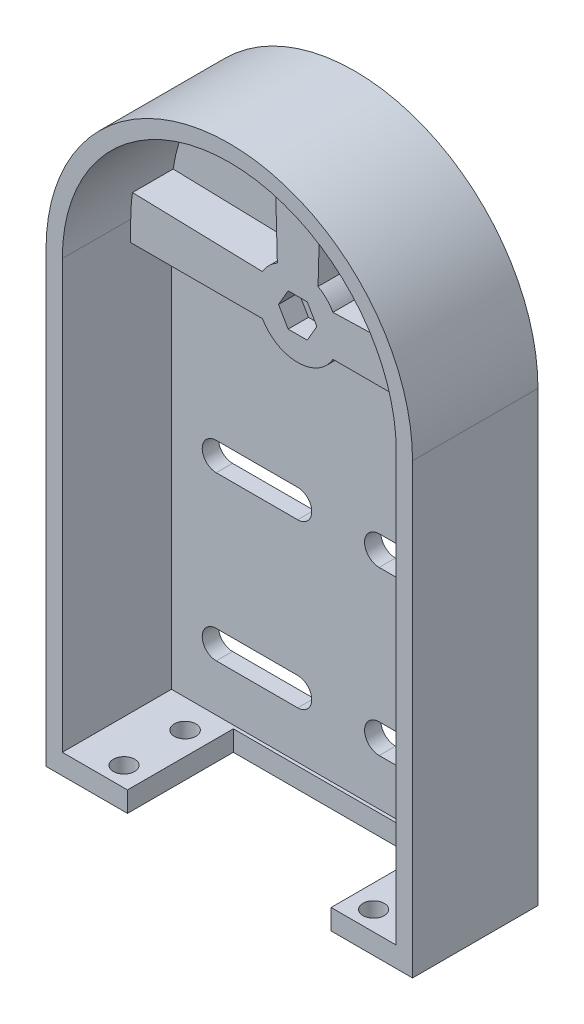
from build123d import *

# Parameters (mm, degrees)
SALIENTE_EXTRUIR1_DEPTH                              = 4
CROQUIS2_R                                           = 2.75
SALIENTE_EXTRUIR2_DEPTH                              = 10
SALIENTE_EXTRUIR3_DEPTH                              = 30.8
CROQUIS4_R                                           = 2.75
CORTAR_EXTRUIR1_DEPTH                                = 4
REFRENTADO_PARA_TORNILLO_TAP_N_CON_CABEZ_D           = 5.5
REFRENTADO_PARA_TORNILLO_TAP_N_CON_CABEZ_CSINK_D     = 11.2
REFRENTADO_PARA_TORNILLO_TAP_N_CON_CABEZ_CSINK_ANGLE = 90
CORTAR_EXTRUIR2_DEPTH                                = 5
CORTAR_EXTRUIR3_DEPTH                                = 5
CORTAR_EXTRUIR4_DEPTH                                = 14
CROQUIS10_W                                          = 82
CROQUIS10_H                                          = 26.8
SALIENTE_EXTRUIR4_DEPTH                              = 5
CROQUIS11_R                                          = 2.619714774
CROQUIS11_W                                          = 50
CROQUIS11_H                                          = 26
CROQUIS11_R_2                                        = 2.655214408
CORTAR_EXTRUIR5_DEPTH                                = 5


with BuildPart() as part:
    # Croquis1 → Saliente-Extruir1 (new body)
    with BuildSketch(Plane.XY):
        with BuildLine():
            Line((-41, 0), (41, 0))
            Line((41, 0), (41, 110))
            ThreePointArc((41, 110), (0, 151), (-41, 110))
            Line((-41, 110), (-41, 0))
        make_face()
    extrude(amount=SALIENTE_EXTRUIR1_DEPTH)

    # Croquis2 → Saliente-Extruir2 (add)
    with BuildSketch(Plane.XY.offset(4)):
        with BuildLine():
            Line((-41, 105), (-8.660254038, 105))
            ThreePointArc((-8.660254038, 105), (0, 100), (8.660254038, 105))
            Line((8.660254038, 105), (41, 105))
            Line((41, 105), (41, 110))
            ThreePointArc((41, 110), (40.894733882, 112.936109791), (40.579476063, 115.857142857))
            Line((40.579476063, 115.857142857), (8.660254038, 115))
            ThreePointArc((8.660254038, 115), (7.071067812, 117.071067812), (5, 118.660254038))
            Line((5, 118.660254038), (5.857142857, 150.579476063))
            ThreePointArc((5.857142857, 150.579476063), (0, 151), (-5.857142857, 150.579476063))
            Line((-5.857142857, 150.579476063), (-5, 118.660254038))
            ThreePointArc((-5, 118.660254038), (-7.071067812, 117.071067812), (-8.660254038, 115))
            Line((-8.660254038, 115), (-40.579476063, 115.857142857))
            ThreePointArc((-40.579476063, 115.857142857), (-40.894733882, 112.936109791), (-41, 110))
            Line((-41, 110), (-41, 105))
        make_face()
        with Locations((0, 110)):
            Circle(CROQUIS2_R, mode=Mode.SUBTRACT)
    extrude(amount=SALIENTE_EXTRUIR2_DEPTH)

    # Croquis3 → Saliente-Extruir3 (add)
    with BuildSketch(Plane(origin=(0, 0, 0), x_dir=(-1, 0, 0), z_dir=(0, 0, -1))):
        with BuildLine():
            Line((-41, 0), (-41, 110))
            ThreePointArc((-41, 110), (0, 151), (41, 110))
            Line((41, 110), (41, 0))
            Line((41, 0), (45, 0))
            Line((45, 0), (45, 110))
            ThreePointArc((45, 110), (0, 155), (-45, 110))
            Line((-45, 110), (-45, 0))
            Line((-45, 0), (-41, 0))
        make_face()
    extrude(amount=-SALIENTE_EXTRUIR3_DEPTH)

    # Croquis4 → Cortar-Extruir1 (cut)
    with BuildSketch(Plane.XY.offset(4)):
        with Locations((0, 110)):
            Circle(CROQUIS4_R)
    extrude(amount=-CORTAR_EXTRUIR1_DEPTH, mode=Mode.SUBTRACT)

    # Refrentado para tornillo tapón con cabeza plana de clavija de M52 (through all)
    with Locations(Plane(origin=(0, 110, 0), x_dir=(-1, 0, 0), z_dir=(0, 0, -1))):
        with Locations((0, 0)):
            CounterSinkHole(REFRENTADO_PARA_TORNILLO_TAP_N_CON_CABEZ_D / 2, REFRENTADO_PARA_TORNILLO_TAP_N_CON_CABEZ_CSINK_D / 2, counter_sink_angle=REFRENTADO_PARA_TORNILLO_TAP_N_CON_CABEZ_CSINK_ANGLE)

    # Croquis7 → Cortar-Extruir2 (cut)
    with BuildSketch(Plane(origin=(0, 0, 0), x_dir=(-1, 0, 0), z_dir=(0, 0, -1))):
        Polygon((2.189291013, 105.834926388), (4.701705063, 109.813444827), (2.512414051, 113.978518439), (-2.189291013, 114.165073612), (-4.701705063, 110.186555173), (-2.512414051, 106.021481561), align=None)
    extrude(amount=-CORTAR_EXTRUIR2_DEPTH, mode=Mode.SUBTRACT)

    # Croquis8 → Cortar-Extruir3 (cut)
    with BuildSketch(Plane.XY.offset(14)):
        Polygon((4.705404694, 110), (2.352702347, 114.075), (-2.352702347, 114.075), (-4.705404694, 110), (-2.352702347, 105.925), (2.352702347, 105.925), align=None)
    extrude(amount=-CORTAR_EXTRUIR3_DEPTH, mode=Mode.SUBTRACT)

    # Croquis9 → Cortar-Extruir4 (cut)
    with BuildSketch(Plane.XY.offset(14)):
        with BuildLine():
            Line((-30, 63.448836188), (-10, 63.448836188))
            ThreePointArc((-10, 63.448836188), (-6.551163812, 60), (-10, 56.551163812))
            Line((-10, 56.551163812), (-30, 56.551163812))
            ThreePointArc((-30, 56.551163812), (-33.448836188, 60), (-30, 63.448836188))
        make_face()
        with BuildLine():
            Line((10, 63.580626855), (30, 63.580626855))
            ThreePointArc((30, 63.580626855), (33.580626855, 60), (30, 56.419373145))
            Line((30, 56.419373145), (10, 56.419373145))
            ThreePointArc((10, 56.419373145), (6.419373145, 60), (10, 63.580626855))
        make_face()
        with BuildLine():
            Line((-30, 16.551163812), (-10, 16.551163812))
            ThreePointArc((-10, 16.551163812), (-6.551163812, 20), (-10, 23.448836188))
            Line((-10, 23.448836188), (-30, 23.448836188))
            ThreePointArc((-30, 23.448836188), (-33.448836188, 20), (-30, 16.551163812))
        make_face()
        with BuildLine():
            Line((10, 16.419373145), (30, 16.419373145))
            ThreePointArc((30, 16.419373145), (33.580626855, 20), (30, 23.580626855))
            Line((30, 23.580626855), (10, 23.580626855))
            ThreePointArc((10, 23.580626855), (6.419373145, 20), (10, 16.419373145))
        make_face()
    extrude(amount=-CORTAR_EXTRUIR4_DEPTH, mode=Mode.SUBTRACT)

    # Croquis10 → Saliente-Extruir4 (add)
    with BuildSketch(Plane(origin=(0, 5, 0), x_dir=(-1, 0, 0), z_dir=(0, -1, 0))):
        with Locations((0, -17.4)):
            Rectangle(CROQUIS10_W, CROQUIS10_H)
    extrude(amount=SALIENTE_EXTRUIR4_DEPTH)

    # Croquis11 → Cortar-Extruir5 (cut)
    with BuildSketch(Plane.XZ):
        with Locations((-30.65, 26)):
            Circle(CROQUIS11_R)
        with Locations((0, 17.8)):
            Rectangle(CROQUIS11_W, CROQUIS11_H)
        with Locations((30.65, 26)):
            Circle(CROQUIS11_R)
        with Locations((30.65, 11)):
            Circle(CROQUIS11_R_2)
        with Locations((-30.65, 11)):
            Circle(CROQUIS11_R_2)
    extrude(amount=-CORTAR_EXTRUIR5_DEPTH, mode=Mode.SUBTRACT)


solid = part.part
